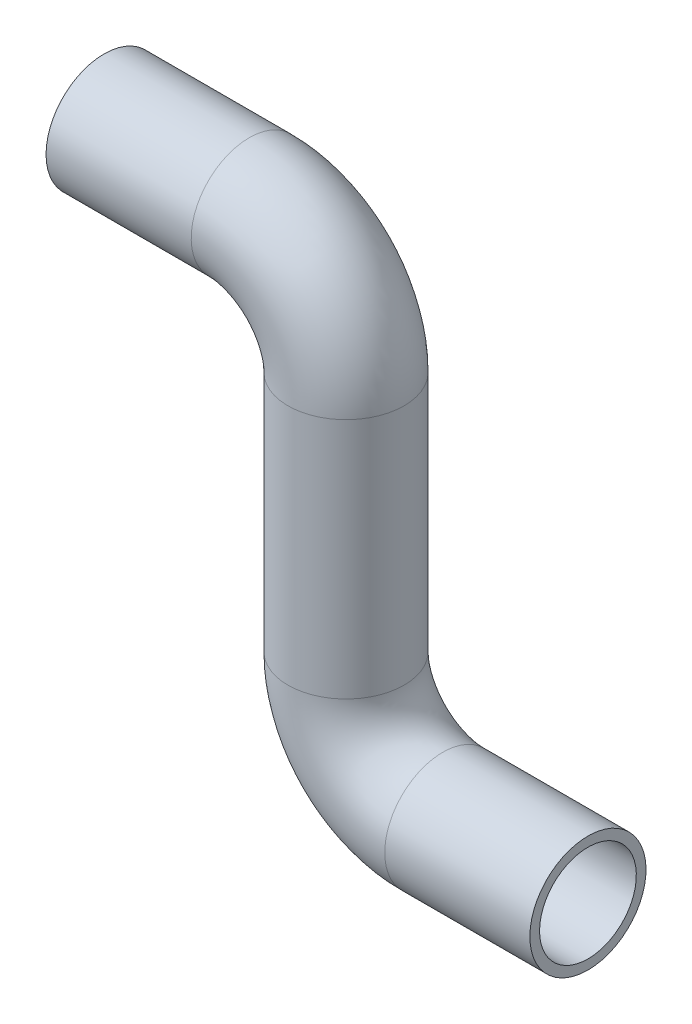
from build123d import *

# Parameters (mm, degrees)
SWEEP_THIN1_PROFILE_R   = 6
SWEEP_THIN1_PROFILE_R_2 = 5


with BuildPart() as part:
    # Sweep-Thin1: sweep along a path in Sketch1
    with BuildLine(Plane.XY) as sweep_thin1_path:
        Line((-25, 45), (-10, 45))
        ThreePointArc((-10, 45), (-2.928932188, 42.071067812), (0, 35))
        Line((0, 35), (0, 10))
        ThreePointArc((0, 10), (2.928932188, 2.928932188), (10, 0))
        Line((10, 0), (25, 0))
    # Sweep-Thin1 profile (on start of the path) → Sweep-Thin1 (sweep)
    with BuildSketch(Plane(origin=(-25, 45, 0), x_dir=(0, 0, 1), z_dir=(1, 0, 0))):
        Circle(SWEEP_THIN1_PROFILE_R)
        Circle(SWEEP_THIN1_PROFILE_R_2, mode=Mode.SUBTRACT)
    sweep(path=sweep_thin1_path.line)


solid = part.part
